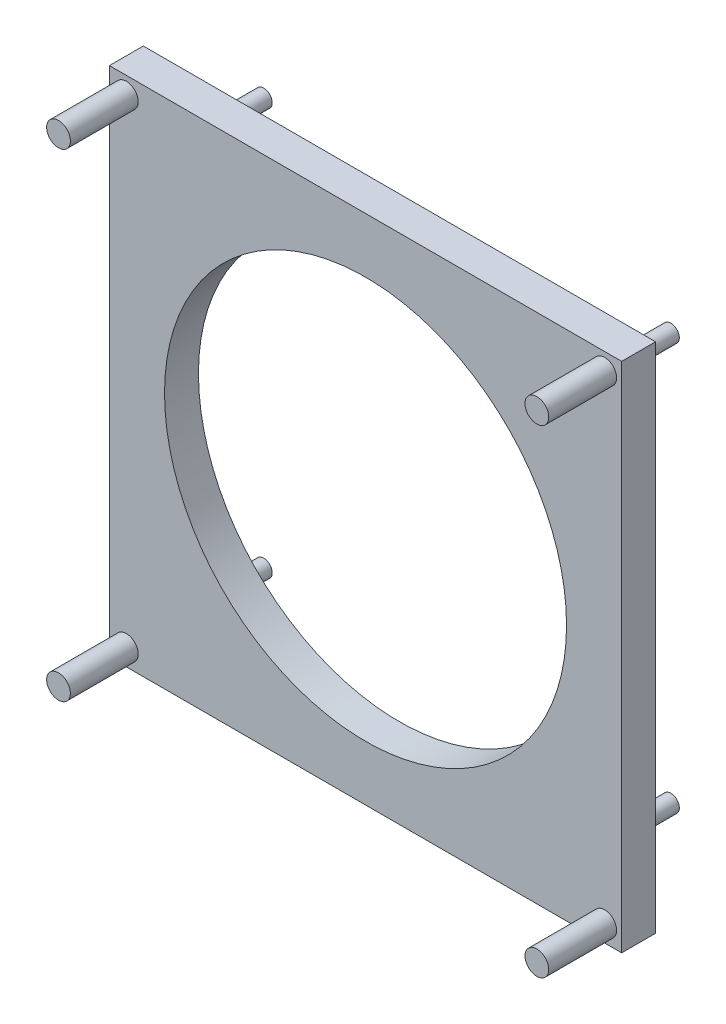
from build123d import *

# Parameters (mm, degrees)
SKETCH1_W           = 151
SKETCH1_H           = 151
BOSS_EXTRUDE1_DEPTH = 10
SKETCH3_R           = 59.25
CUT_EXTRUDE1_DEPTH  = 11
SKETCH4_R           = 3.5
BOSS_EXTRUDE2_DEPTH = 20
SKETCH5_R           = 2.5
BOSS_EXTRUDE3_DEPTH = 20


with BuildPart() as part:
    # Sketch1 → Boss-Extrude1 (new body)
    with BuildSketch(Plane.XY):
        with Locations((-150.258224199, 52.751753825)):
            Rectangle(SKETCH1_W, SKETCH1_H)
    extrude(amount=BOSS_EXTRUDE1_DEPTH)

    # Sketch3 → Cut-Extrude1 (cut, through all)
    with BuildSketch(Plane.XY.offset(10)):
        with Locations((-150.258224199, 52.751753825)):
            Circle(SKETCH3_R)
    extrude(amount=-CUT_EXTRUDE1_DEPTH, mode=Mode.SUBTRACT)

    # Sketch4 → Boss-Extrude2 (add)
    with BuildSketch(Plane.XY.offset(10)):
        with Locations((-79.758224199, -17.748246175)):
            Circle(SKETCH4_R)
        with Locations((-220.758224199, -17.748246175)):
            Circle(SKETCH4_R)
        with Locations((-79.758224199, 123.251753825)):
            Circle(SKETCH4_R)
        with Locations((-220.758224199, 123.251753825)):
            Circle(SKETCH4_R)
    extrude(amount=BOSS_EXTRUDE2_DEPTH)

    # Sketch5 → Boss-Extrude3 (add)
    with BuildSketch(Plane(origin=(0, 0, 0), x_dir=(-1, 0, 0), z_dir=(0, 0, -1))):
        with Locations((90.258224199, -7.248246175)):
            Circle(SKETCH5_R)
        with Locations((90.258224199, 112.751753825)):
            Circle(SKETCH5_R)
        with Locations((210.258224199, 112.751753825)):
            Circle(SKETCH5_R)
        with Locations((210.258224199, -7.248246175)):
            Circle(SKETCH5_R)
    extrude(amount=BOSS_EXTRUDE3_DEPTH)


solid = part.part
